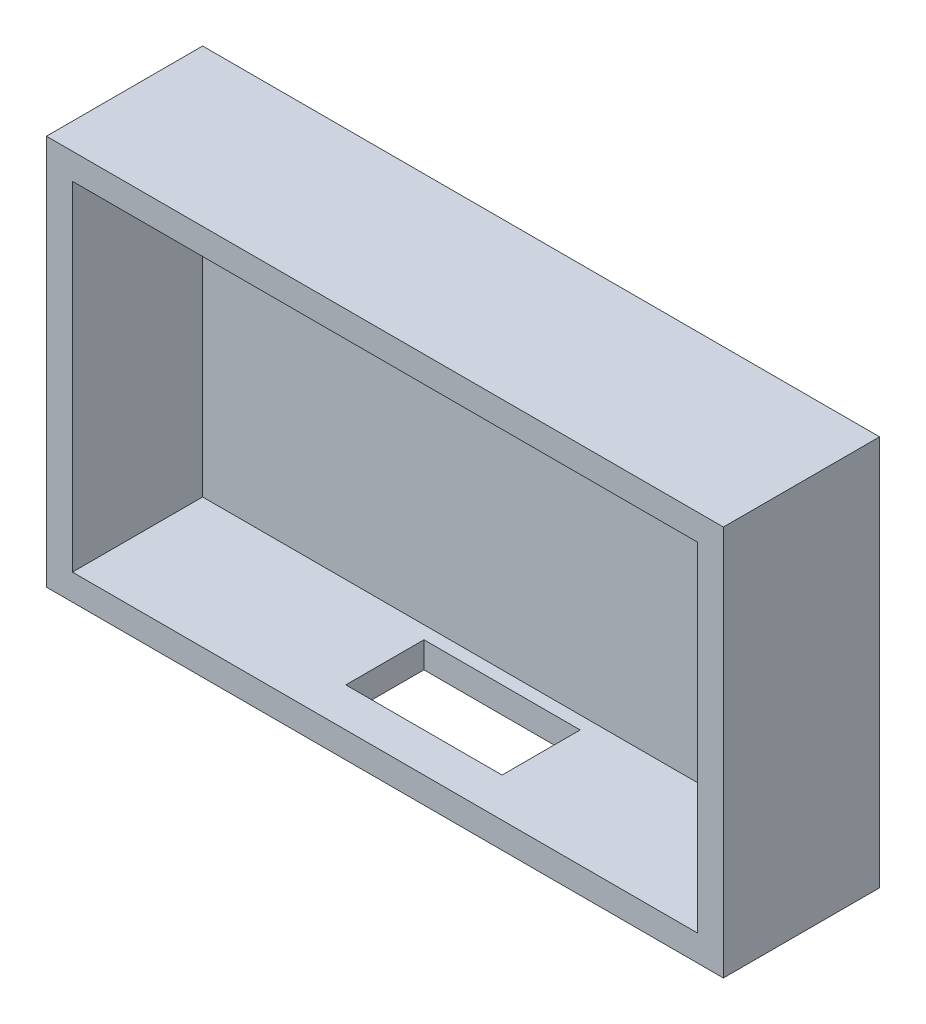
from build123d import *

# Parameters (mm, degrees)
SKETCH1_W           = 130
SKETCH1_H           = 30
BOSS_EXTRUDE1_DEPTH = 75
SHELL1_T            = -5
CUT_EXTRUDE1_REACH  = 77
SKETCH2_W           = 30
SKETCH2_H           = 15


with BuildPart() as part:
    # Sketch1 → Boss-Extrude1 (new body)
    with BuildSketch(Plane(origin=(0, 0, 0), x_dir=(1, 0, 0), z_dir=(0, 1, 0))):
        with Locations((65, 15)):
            Rectangle(SKETCH1_W, SKETCH1_H)
    extrude(amount=BOSS_EXTRUDE1_DEPTH)

    # Shell1
    shell1_openings = [part.faces().sort_by_distance(p)[0] for p in [
        (65, 37.5, 0),
    ]]
    offset(amount=SHELL1_T, openings=shell1_openings, kind=Kind.INTERSECTION)

    # Sketch2 → Cut-Extrude1 (cut, up to next)
    with BuildSketch(Plane.XZ, mode=Mode.PRIVATE) as cut_extrude1_sk1:
        with Locations((65, -15)):
            Rectangle(SKETCH2_W, SKETCH2_H)
    cut_extrude1_tool1 = extrude(cut_extrude1_sk1.sketch, amount=-CUT_EXTRUDE1_REACH, mode=Mode.PRIVATE) & part.part
    add(cut_extrude1_tool1.solids().sort_by_distance((65, 0, -15))[0], mode=Mode.SUBTRACT)


solid = part.part
